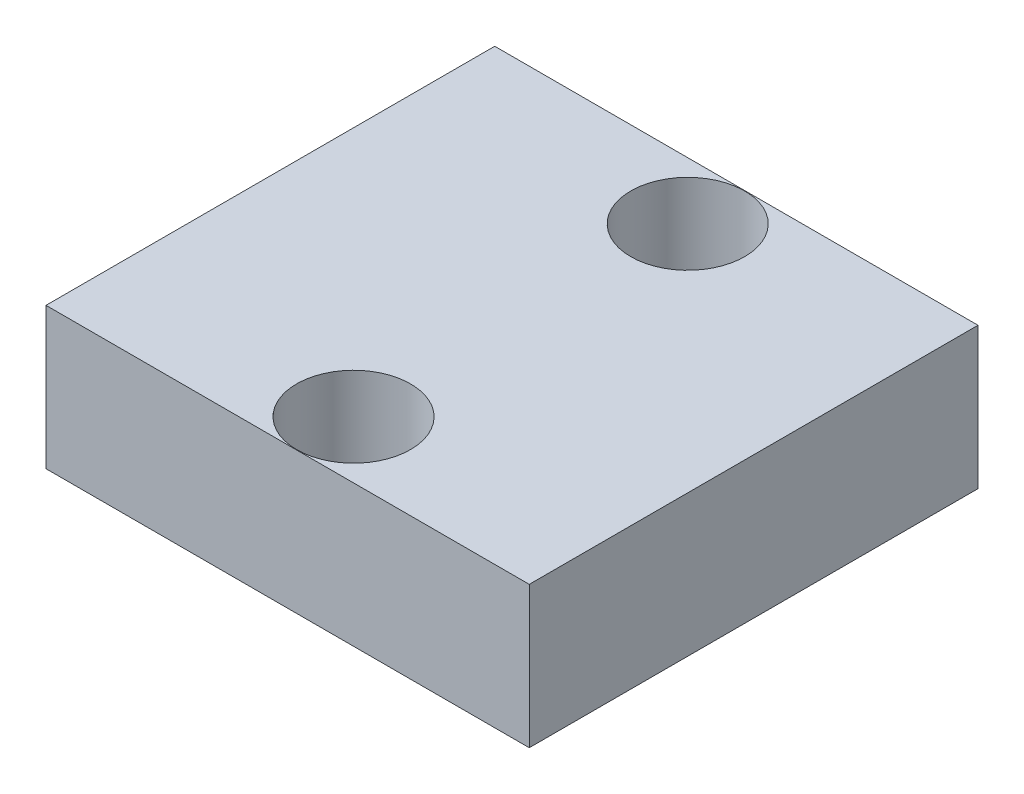
from build123d import *

# Parameters (mm, degrees)
SKETCH1_W           = 14
SKETCH1_H           = 13
SKETCH1_R           = 1.65
BOSS_EXTRUDE3_DEPTH = 4.1


with BuildPart() as part:
    # Sketch1 → Boss-Extrude3 (new body)
    with BuildSketch(Plane(origin=(0, 0, 0), x_dir=(1, 0, 0), z_dir=(0, 1, 0))):
        Rectangle(SKETCH1_W, SKETCH1_H)
        with Locations((0.25, 4.84)):
            Circle(SKETCH1_R, mode=Mode.SUBTRACT)
        with Locations((0.25, -4.84)):
            Circle(SKETCH1_R, mode=Mode.SUBTRACT)
    extrude(amount=BOSS_EXTRUDE3_DEPTH)


solid = part.part
